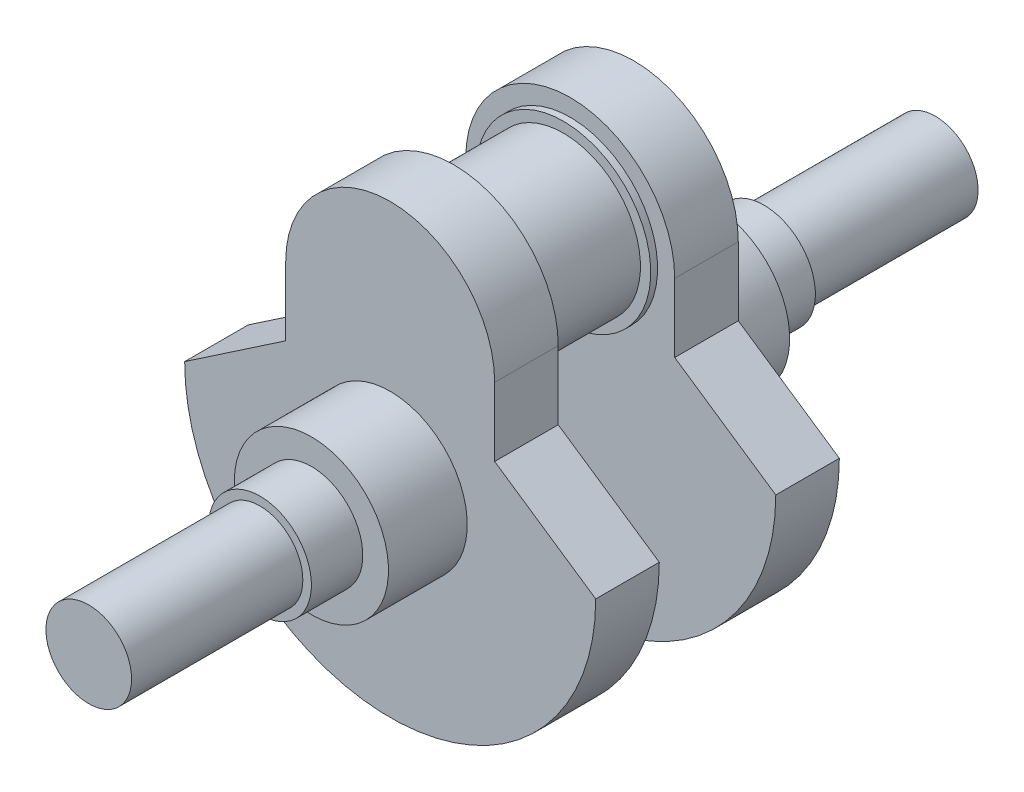
from build123d import *

# Parameters (mm, degrees)
SKETCH1_R            = 12.5
BOSS_EXTRUDE1_DEPTH  = 50
SKETCH3_R            = 15
BOSS_EXTRUDE2_DEPTH  = 15
SKETCH4_R            = 22.5
BOSS_EXTRUDE3_DEPTH  = 23
SKETCH5_R            = 22.5
BOSS_EXTRUDE5_DEPTH  = 18.56
SKETCH6_R            = 22.5
BOSS_EXTRUDE6_DEPTH  = 18.56
SKETCH7_R            = 25.5
BOSS_EXTRUDE7_DEPTH  = 2
SKETCH9_R            = 22.5
BOSS_EXTRUDE8_DEPTH  = 30
SKETCH11_R           = 25.5
BOSS_EXTRUDE9_DEPTH  = 2
BOSS_EXTRUDE10_DEPTH = 18.56
SKETCH13_R           = 22.5
BOSS_EXTRUDE11_DEPTH = 23
SKETCH14_R           = 15
BOSS_EXTRUDE12_DEPTH = 15
SKETCH15_R           = 12.5
BOSS_EXTRUDE13_DEPTH = 50


with BuildPart() as part:
    # Sketch1 → Boss-Extrude1 (new body)
    with BuildSketch(Plane.XY):
        Circle(SKETCH1_R)
    extrude(amount=-BOSS_EXTRUDE1_DEPTH)

    # Sketch3 → Boss-Extrude2 (add)
    with BuildSketch(Plane(origin=(0, 0, -50), x_dir=(-1, 0, 0), z_dir=(0, 0, -1))):
        Circle(SKETCH3_R)
    extrude(amount=BOSS_EXTRUDE2_DEPTH)

    # Sketch4 → Boss-Extrude3 (add)
    with BuildSketch(Plane(origin=(0, 0, -65), x_dir=(-1, 0, 0), z_dir=(0, 0, -1))):
        Circle(SKETCH4_R)
    extrude(amount=BOSS_EXTRUDE3_DEPTH)



with BuildPart() as body_2:
    # Sketch5 → Boss-Extrude5 (new body)
    with BuildSketch(Plane(origin=(0, 0, -88), x_dir=(-1, 0, 0), z_dir=(0, 0, -1))):
        with BuildLine():
            ThreePointArc((30.5, 40), (0, 70.5), (-30.5, 40))
            Line((-30.5, 40), (-30.5, 20))
            Line((-30.5, 20), (-59.999999922, -0.003051235))
            ThreePointArc((-59.999999922, -0.003051235), (0.001525617, -59.999999981), (60, 0))
            Line((60, 0), (30.5, 20))
            Line((30.5, 20), (30.5, 40))
        make_face()
        Circle(SKETCH5_R, mode=Mode.SUBTRACT)
    extrude(amount=BOSS_EXTRUDE5_DEPTH)


with BuildPart() as part_1:
    add(part.part)

    add(body_2.part)  # Boss-Extrude6 merges body 2
    # Sketch6 → Boss-Extrude6 (add)
    with BuildSketch(Plane(origin=(0, 0, -106.56), x_dir=(-1, 0, 0), z_dir=(0, 0, -1))):
        Circle(SKETCH6_R)
    extrude(amount=-BOSS_EXTRUDE6_DEPTH)

    # Sketch7 → Boss-Extrude7 (add)
    with BuildSketch(Plane(origin=(0, 0, -106.56), x_dir=(-1, 0, 0), z_dir=(0, 0, -1))):
        with Locations((0, 40)):
            Circle(SKETCH7_R)
    extrude(amount=BOSS_EXTRUDE7_DEPTH)

    # Sketch9 → Boss-Extrude8 (add)
    with BuildSketch(Plane(origin=(0, 0, -108.56), x_dir=(-1, 0, 0), z_dir=(0, 0, -1))):
        with Locations((0, 40)):
            Circle(SKETCH9_R)
    extrude(amount=BOSS_EXTRUDE8_DEPTH)

    # Sketch11 → Boss-Extrude9 (add)
    with BuildSketch(Plane(origin=(0, 0, -138.56), x_dir=(-1, 0, 0), z_dir=(0, 0, -1))):
        with Locations((0, 40)):
            Circle(SKETCH11_R)
    extrude(amount=BOSS_EXTRUDE9_DEPTH)

    # Sketch12 → Boss-Extrude10 (add)
    with BuildSketch(Plane(origin=(0, 0, -140.56), x_dir=(-1, 0, 0), z_dir=(0, 0, -1))):
        with BuildLine():
            Line((-30.5, 40), (-30.5, 20))
            Line((-30.5, 20), (-60, 0))
            ThreePointArc((-60, 0), (0, -60), (60, 0))
            Line((60, 0), (30.5, 20))
            Line((30.5, 20), (30.5, 40))
            ThreePointArc((30.5, 40), (0, 70.5), (-30.5, 40))
        make_face()
    extrude(amount=BOSS_EXTRUDE10_DEPTH)

    # Sketch13 → Boss-Extrude11 (add)
    with BuildSketch(Plane(origin=(0, 0, -159.12), x_dir=(-1, 0, 0), z_dir=(0, 0, -1))):
        Circle(SKETCH13_R)
    extrude(amount=BOSS_EXTRUDE11_DEPTH)

    # Sketch14 → Boss-Extrude12 (add)
    with BuildSketch(Plane(origin=(0, 0, -182.12), x_dir=(-1, 0, 0), z_dir=(0, 0, -1))):
        Circle(SKETCH14_R)
    extrude(amount=BOSS_EXTRUDE12_DEPTH)

    # Sketch15 → Boss-Extrude13 (add)
    with BuildSketch(Plane(origin=(0, 0, -197.12), x_dir=(-1, 0, 0), z_dir=(0, 0, -1))):
        Circle(SKETCH15_R)
    extrude(amount=BOSS_EXTRUDE13_DEPTH)


solid = part_1.part
